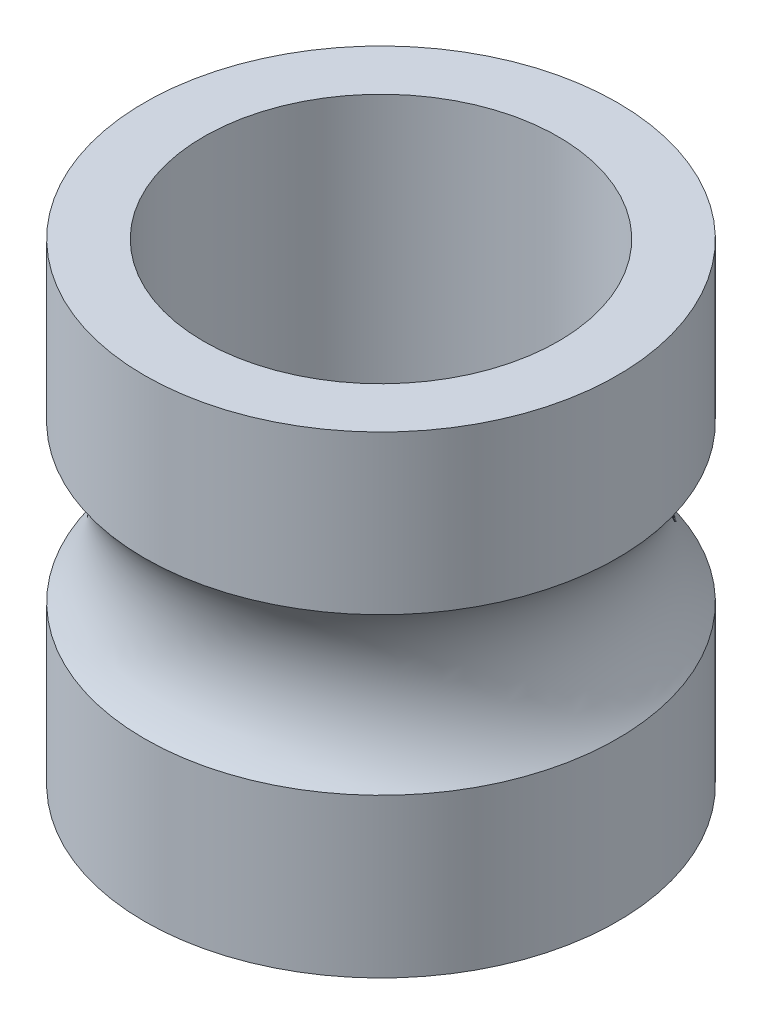
from build123d import *

# Parameters (mm, degrees)
DIAPROFILES_R         = 2
DIAPROFILES_R_2       = 1.5
DIAPROFILE_DEPTH      = 2
BEARINGPATHPROFILES_R = 1


with BuildPart() as part:
    # DiaProfileS → DiaProfile (new body, symmetric)
    with BuildSketch(Plane(origin=(0, 0, 0), x_dir=(1, 0, 0), z_dir=(0, 1, 0))):
        Circle(DIAPROFILES_R)
        Circle(DIAPROFILES_R_2, mode=Mode.SUBTRACT)
    extrude(amount=DIAPROFILE_DEPTH, both=True)

    # BearingPathProfileS → BearingPathProfile (revolve, cut)
    with BuildSketch(Plane.XY):
        with Locations((2.75, 0)):
            Circle(BEARINGPATHPROFILES_R)
    revolve(axis=Axis((0, 2, 0), (0, -1, 0)), mode=Mode.SUBTRACT)


solid = part.part
